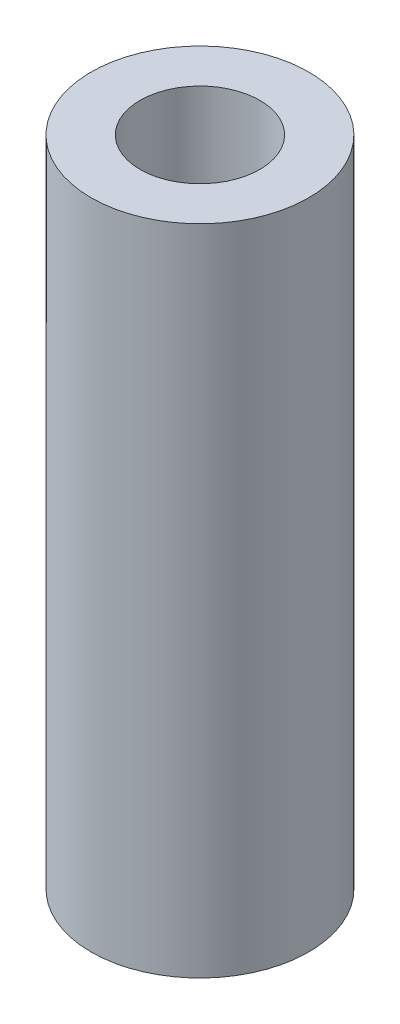
from build123d import *

# Parameters (mm, degrees)
SKETCH1_R           = 10
SKETCH1_R_2         = 5.5
BOSS_EXTRUDE1_DEPTH = 60
SKETCH1_2_R         = 5.5
BOSS_EXTRUDE2_DEPTH = 10


with BuildPart() as part:
    # Sketch1 → Boss-Extrude1 (new body)
    with BuildSketch(Plane(origin=(0, 0, 0), x_dir=(1, 0, 0), z_dir=(0, 1, 0))):
        Circle(SKETCH1_R)
        Circle(SKETCH1_R_2, mode=Mode.SUBTRACT)
    extrude(amount=BOSS_EXTRUDE1_DEPTH)

    # Sketch1_2 → Boss-Extrude2 (add)
    with BuildSketch(Plane(origin=(0, 0, 0), x_dir=(1, 0, 0), z_dir=(0, 1, 0))):
        Circle(SKETCH1_2_R)
    extrude(amount=BOSS_EXTRUDE2_DEPTH)


solid = part.part
